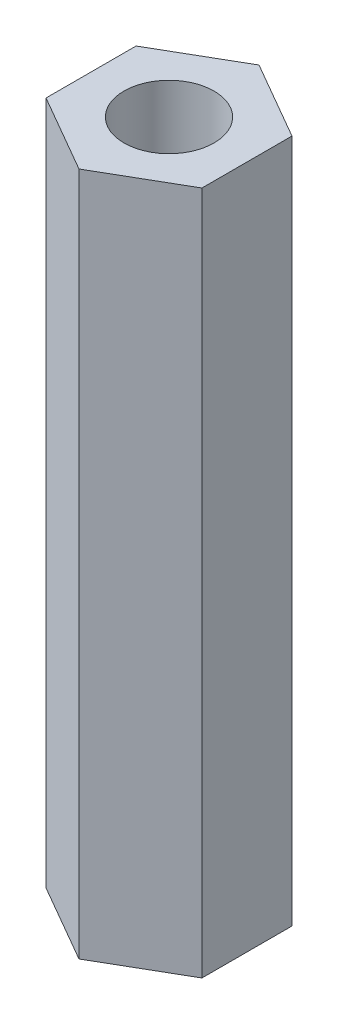
from build123d import *

# Parameters (mm, degrees)
ESQUISSE1_R      = 2.5
EXTRUSION1_DEPTH = 38


with BuildPart() as part:
    # Esquisse1 → Extrusion1 (new body)
    with BuildSketch(Plane(origin=(0, 0, 0), x_dir=(1, 0, 0), z_dir=(0, 1, 0))):
        Polygon((0, 5), (-4.330127019, 2.5), (-4.330127019, -2.5), (0, -5), (4.330127019, -2.5), (4.330127019, 2.5), align=None)
        Circle(ESQUISSE1_R, mode=Mode.SUBTRACT)
    extrude(amount=EXTRUSION1_DEPTH)


solid = part.part
